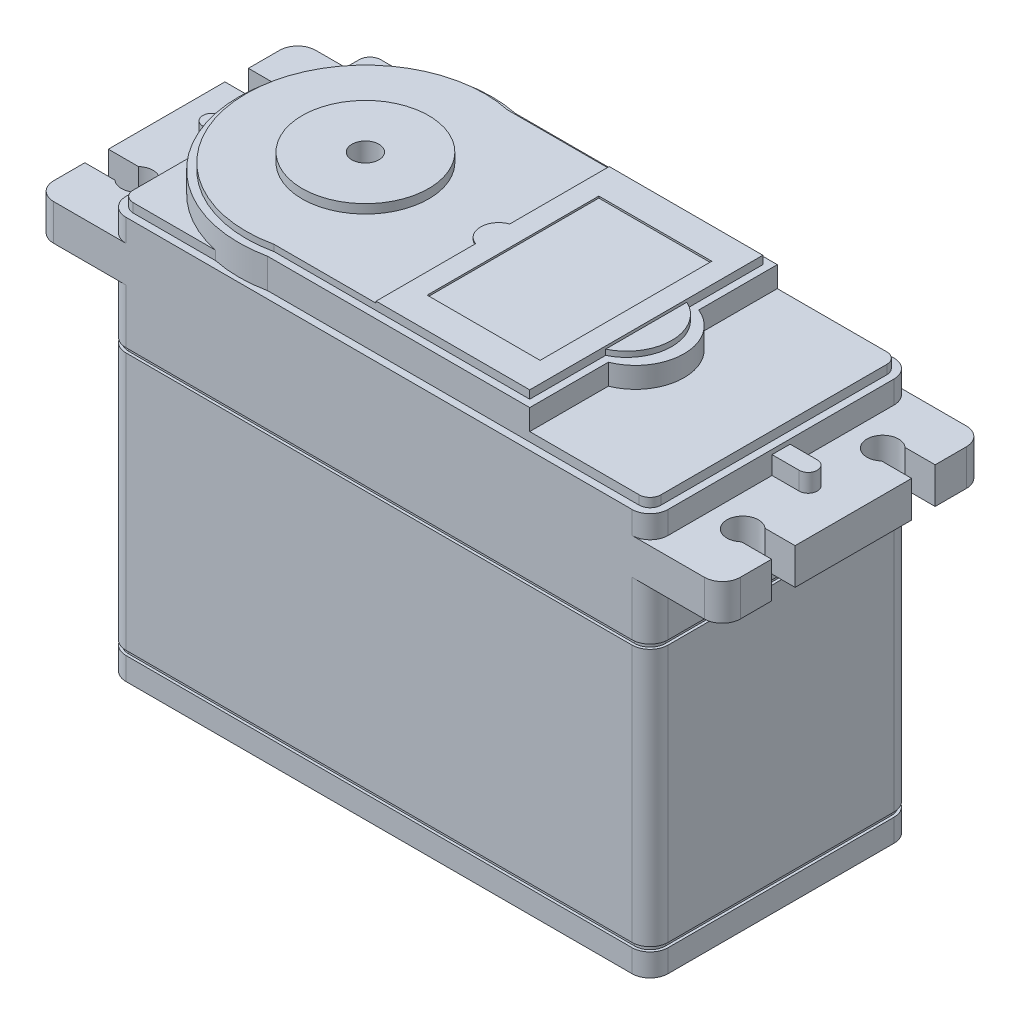
from build123d import *

# Parameters (mm, degrees)
SKETCH2_W            = 60
SKETCH2_H            = 29
BOSS_EXTRUDE1_DEPTH  = 46.5
FILLET1_R            = 2
BOSS_EXTRUDE2_DEPTH  = 4
BOSS_EXTRUDE3_DEPTH  = 2
CUT_EXTRUDE1_DEPTH   = 1
BOSS_EXTRUDE4_START  = -1
BOSS_EXTRUDE4_DEPTH  = 4
CUT_EXTRUDE2_DEPTH   = 0.7
BOSS_EXTRUDE5_REACH  = 50.8
BOSS_EXTRUDE6_DEPTH  = 0.6
CUT_EXTRUDE3_DEPTH   = 0.5
CUT_EXTRUDE4_DEPTH   = 0.5
CHAMFER1_SIZE        = 1
CUT_EXTRUDE5_DEPTH   = 1
SKETCH15_R           = 2
BOSS_EXTRUDE7_DEPTH  = 0.9
FILLET2_R            = 0.3
SKETCH16_R           = 7
BOSS_EXTRUDE8_DEPTH  = 1
SKETCH17_R           = 1.5
CUT_EXTRUDE6_DEPTH   = 10
BOSS_EXTRUDE9_DEPTH  = 0.2
SKETCH19_W           = 12.5
SKETCH19_H           = 19
CUT_EXTRUDE7_DEPTH   = 0.2
SKETCH21_W           = 6.5
SKETCH21_H           = 4.5
BOSS_EXTRUDE10_DEPTH = 5.2
CUT_EXTRUDE13_REACH  = 19.75
SKETCH25_W           = 5.5
SKETCH25_H           = 1.5
CUT_EXTRUDE14_DEPTH  = 7.2


with BuildPart() as part:
    # Sketch2 → Boss-Extrude1 (new body)
    with BuildSketch(Plane(origin=(0, 0, 0), x_dir=(1, 0, 0), z_dir=(0, 1, 0))):
        Rectangle(SKETCH2_W, SKETCH2_H)
    extrude(amount=BOSS_EXTRUDE1_DEPTH)

    # Fillet1
    fillet1_edges = [part.edges().sort_by_distance(p)[0] for p in [
        (30, 23.25, 14.5),
        (-30, 23.25, 14.5),
        (-30, 23.25, -14.5),
        (30, 23.25, -14.5),
    ]]
    fillet(fillet1_edges, radius=FILLET1_R)

    # Sketch4 → Boss-Extrude2 (add)
    with BuildSketch(Plane(origin=(0, 43, 0), x_dir=(1, 0, 0), z_dir=(0, 1, 0))):
        with BuildLine():
            Line((28, 14.5), (36, 14.5))
            ThreePointArc((36, 14.5), (37.414213562, 13.914213562), (38, 12.5))
            Line((38, 12.5), (38, 9.05))
            Line((38, 9.05), (34.671537451, 9.05))
            ThreePointArc((34.671537451, 9.05), (31.75, 7.75), (34.671537451, 6.45))
            Line((34.671537451, 6.45), (38, 6.45))
            Line((38, 6.45), (38, -6.45))
            Line((38, -6.45), (34.671537451, -6.45))
            ThreePointArc((34.671537451, -6.45), (31.75, -7.75), (34.671537451, -9.05))
            Line((34.671537451, -9.05), (38, -9.05))
            Line((38, -9.05), (38, -12.5))
            ThreePointArc((38, -12.5), (37.414213562, -13.914213562), (36, -14.5))
            Line((36, -14.5), (28, -14.5))
            ThreePointArc((28, -14.5), (29.414213562, -13.914213562), (30, -12.5))
            Line((30, -12.5), (30, 12.5))
            ThreePointArc((30, 12.5), (29.414213562, 13.914213562), (28, 14.5))
        make_face()
        with BuildLine():
            Line((-30, -12.5), (-30, 12.5))
            ThreePointArc((-30, 12.5), (-29.414213562, 13.914213562), (-28, 14.5))
            Line((-28, 14.5), (-36, 14.5))
            ThreePointArc((-36, 14.5), (-37.414213562, 13.914213562), (-38, 12.5))
            Line((-38, 12.5), (-38, 9.05))
            Line((-38, 9.05), (-34.671537451, 9.05))
            ThreePointArc((-34.671537451, 9.05), (-31.75, 7.75), (-34.671537451, 6.45))
            Line((-34.671537451, 6.45), (-38, 6.45))
            Line((-38, 6.45), (-38, -6.45))
            Line((-38, -6.45), (-34.671537451, -6.45))
            ThreePointArc((-34.671537451, -6.45), (-31.75, -7.75), (-34.671537451, -9.05))
            Line((-34.671537451, -9.05), (-38, -9.05))
            Line((-38, -9.05), (-38, -12.5))
            ThreePointArc((-38, -12.5), (-37.414213562, -13.914213562), (-36, -14.5))
            Line((-36, -14.5), (-28, -14.5))
            ThreePointArc((-28, -14.5), (-29.414213562, -13.914213562), (-30, -12.5))
        make_face()
    extrude(amount=-BOSS_EXTRUDE2_DEPTH)

    # Sketch5 → Boss-Extrude3 (add)
    with BuildSketch(Plane(origin=(0, 43, 0), x_dir=(1, 0, 0), z_dir=(0, 1, 0))):
        with BuildLine():
            Line((30, 1), (33, 1))
            ThreePointArc((33, 1), (34, 0), (33, -1))
            Line((33, -1), (30, -1))
            Line((30, -1), (30, 1))
        make_face()
        with BuildLine():
            Line((-30, 1), (-30, -1))
            Line((-30, -1), (-33, -1))
            ThreePointArc((-33, -1), (-34, 0), (-33, 1))
            Line((-33, 1), (-30, 1))
        make_face()
    extrude(amount=BOSS_EXTRUDE3_DEPTH)

    # Sketch6 → Cut-Extrude1 (cut)
    with BuildSketch(Plane(origin=(0, 46.5, 0), x_dir=(1, 0, 0), z_dir=(0, 1, 0))):
        with BuildLine():
            ThreePointArc((30, 12.5), (29.414213562, 13.914213562), (28, 14.5))
            Line((28, 14.5), (-28, 14.5))
            ThreePointArc((-28, 14.5), (-29.414213562, 13.914213562), (-30, 12.5))
            Line((-30, 12.5), (-30, -12.5))
            ThreePointArc((-30, -12.5), (-29.414213562, -13.914213562), (-28, -14.5))
            Line((-28, -14.5), (28, -14.5))
            ThreePointArc((28, -14.5), (29.414213562, -13.914213562), (30, -12.5))
            Line((30, -12.5), (30, 12.5))
        make_face()
        with BuildLine():
            ThreePointArc((29.2, 12.5), (28.848528137, 13.348528137), (28, 13.7))
            Line((28, 13.7), (-28, 13.7))
            ThreePointArc((-28, 13.7), (-28.848528137, 13.348528137), (-29.2, 12.5))
            Line((-29.2, 12.5), (-29.2, -12.5))
            ThreePointArc((-29.2, -12.5), (-28.848528137, -13.348528137), (-28, -13.7))
            Line((-28, -13.7), (28, -13.7))
            ThreePointArc((28, -13.7), (28.848528137, -13.348528137), (29.2, -12.5))
            Line((29.2, -12.5), (29.2, 12.5))
        make_face(mode=Mode.SUBTRACT)
    extrude(amount=-CUT_EXTRUDE1_DEPTH, mode=Mode.SUBTRACT)

    # Sketch7 → Boss-Extrude4 (add)
    with BuildSketch(Plane(origin=(0, 46.5, 0), x_dir=(1, 0, 0), z_dir=(0, 1, 0)).offset(BOSS_EXTRUDE4_START)):
        with BuildLine():
            Line((15.882707061, 13.7), (-13.117292939, 13.7))
            ThreePointArc((-13.117292939, 13.7), (-30, 0), (-13.117292939, -13.7))
            Line((-13.117292939, -13.7), (15.882707061, -13.7))
            Line((15.882707061, -13.7), (15.882707061, 13.7))
        make_face()
    extrude(amount=BOSS_EXTRUDE4_DEPTH)

    # Sketch8 → Cut-Extrude2 (cut)
    with BuildSketch(Plane(origin=(0, 49.5, 0), x_dir=(1, 0, 0), z_dir=(0, 1, 0))):
        with BuildLine():
            Line((15.882707061, -13.7), (15.882707061, 13.7))
            Line((15.882707061, 13.7), (-13.117292939, 13.7))
            ThreePointArc((-13.117292939, 13.7), (-30, 0), (-13.117292939, -13.7))
            Line((-13.117292939, -13.7), (15.882707061, -13.7))
        make_face()
        with BuildLine():
            Line((-13.201786284, -12.9), (15.082707061, -12.9))
            Line((15.082707061, -12.9), (15.082707061, 12.9))
            Line((15.082707061, 12.9), (-13.201786284, 12.9))
            ThreePointArc((-13.201786284, 12.9), (-29.2, 0), (-13.201786284, -12.9))
        make_face(mode=Mode.SUBTRACT)
    extrude(amount=-CUT_EXTRUDE2_DEPTH, mode=Mode.SUBTRACT)

    # Sketch9 → Boss-Extrude5 (add, up to next)
    with BuildSketch(Plane(origin=(0, 48.8, 0), x_dir=(1, 0, 0), z_dir=(0, 1, 0)), mode=Mode.PRIVATE) as boss_extrude5_sk1:
        with BuildLine():
            Line((15.882707061, 5), (15.882707061, -5))
            ThreePointArc((15.882707061, -5), (19.267871868, 0), (15.882707061, 5))
        make_face()
    boss_extrude5_tool1 = extrude(boss_extrude5_sk1.sketch, amount=-BOSS_EXTRUDE5_REACH, mode=Mode.PRIVATE) - part.part
    add(boss_extrude5_tool1.solids().sort_by_distance((17.281514, 48.8, 0))[0])

    # Sketch10 → Boss-Extrude6 (add)
    with BuildSketch(Plane(origin=(0, 48.8, 0), x_dir=(1, 0, 0), z_dir=(0, 1, 0))):
        with BuildLine():
            Line((15.082707061, 4.5), (15.082707061, -4.5))
            ThreePointArc((15.082707061, -4.5), (17.903257589, 0), (15.082707061, 4.5))
        make_face()
    extrude(amount=BOSS_EXTRUDE6_DEPTH)

    # Sketch11 → Cut-Extrude3 (cut)
    with BuildSketch(Plane(origin=(0, 3.5, 0), x_dir=(1, 0, 0), z_dir=(0, 1, 0))):
        with BuildLine():
            Line((-30, 12.5), (-30, -12.5))
            ThreePointArc((-30, -12.5), (-29.414213562, -13.914213562), (-28, -14.5))
            Line((-28, -14.5), (28, -14.5))
            ThreePointArc((28, -14.5), (29.414213562, -13.914213562), (30, -12.5))
            Line((30, -12.5), (30, 12.5))
            ThreePointArc((30, 12.5), (29.414213562, 13.914213562), (28, 14.5))
            Line((28, 14.5), (-28, 14.5))
            ThreePointArc((-28, 14.5), (-29.414213562, 13.914213562), (-30, 12.5))
        make_face()
        with BuildLine():
            Line((-28, -14.2), (28, -14.2))
            ThreePointArc((28, -14.2), (29.202081528, -13.702081528), (29.7, -12.5))
            Line((29.7, -12.5), (29.7, 12.5))
            ThreePointArc((29.7, 12.5), (29.202081528, 13.702081528), (28, 14.2))
            Line((28, 14.2), (-28, 14.2))
            ThreePointArc((-28, 14.2), (-29.202081528, 13.702081528), (-29.7, 12.5))
            Line((-29.7, 12.5), (-29.7, -12.5))
            ThreePointArc((-29.7, -12.5), (-29.202081528, -13.702081528), (-28, -14.2))
        make_face(mode=Mode.SUBTRACT)
    extrude(amount=CUT_EXTRUDE3_DEPTH, mode=Mode.SUBTRACT)

    # Sketch12 → Cut-Extrude4 (cut)
    with BuildSketch(Plane(origin=(0, 33, 0), x_dir=(1, 0, 0), z_dir=(0, 1, 0))):
        with BuildLine():
            Line((-30, 12.5), (-30, -12.5))
            ThreePointArc((-30, -12.5), (-29.414213562, -13.914213562), (-28, -14.5))
            Line((-28, -14.5), (28, -14.5))
            ThreePointArc((28, -14.5), (29.414213562, -13.914213562), (30, -12.5))
            Line((30, -12.5), (30, 12.5))
            ThreePointArc((30, 12.5), (29.414213562, 13.914213562), (28, 14.5))
            Line((28, 14.5), (-28, 14.5))
            ThreePointArc((-28, 14.5), (-29.414213562, 13.914213562), (-30, 12.5))
        make_face()
        with BuildLine():
            Line((28, 14.2), (-28, 14.2))
            ThreePointArc((-28, 14.2), (-29.202081528, 13.702081528), (-29.7, 12.5))
            Line((-29.7, 12.5), (-29.7, -12.5))
            ThreePointArc((-29.7, -12.5), (-29.202081528, -13.702081528), (-28, -14.2))
            Line((-28, -14.2), (28, -14.2))
            ThreePointArc((28, -14.2), (29.202081528, -13.702081528), (29.7, -12.5))
            Line((29.7, -12.5), (29.7, 12.5))
            ThreePointArc((29.7, 12.5), (29.202081528, 13.702081528), (28, 14.2))
        make_face(mode=Mode.SUBTRACT)
    extrude(amount=-CUT_EXTRUDE4_DEPTH, mode=Mode.SUBTRACT)

    # Chamfer1
    chamfer1_edges = [part.edges().sort_by_distance(p)[0] for p in [
        (-30, 0, 0),
        (30, 0, 0),
        (0, 0, 14.5),
        (0, 0, -14.5),
        (29.414213562, 0, 13.914213562),
        (29.414213562, 0, -13.914213562),
        (-29.414213562, 0, 13.914213562),
        (-29.414213562, 0, -13.914213562),
    ]]
    chamfer(chamfer1_edges, length=CHAMFER1_SIZE)

    # Sketch14 → Cut-Extrude5 (cut)
    with BuildSketch(Plane.XZ):
        with BuildLine():
            Line((-30, 8.1), (-25, 8.1))
            ThreePointArc((-25, 8.1), (-24.010050506, 8.510050506), (-23.6, 9.5))
            Line((-23.6, 9.5), (-23.6, 14.5))
            Line((-23.6, 14.5), (-28, 14.5))
            ThreePointArc((-28, 14.5), (-29.414213562, 13.914213562), (-30, 12.5))
            Line((-30, 12.5), (-30, 8.1))
        make_face()
        with BuildLine():
            Line((30, 8.1), (30, 12.5))
            ThreePointArc((30, 12.5), (29.414213562, 13.914213562), (28, 14.5))
            Line((28, 14.5), (23.6, 14.5))
            Line((23.6, 14.5), (23.6, 9.5))
            ThreePointArc((23.6, 9.5), (24.010050506, 8.510050506), (25, 8.1))
            Line((25, 8.1), (30, 8.1))
        make_face()
        with BuildLine():
            Line((30, -8.1), (25, -8.1))
            ThreePointArc((25, -8.1), (24.010050506, -8.510050506), (23.6, -9.5))
            Line((23.6, -9.5), (23.6, -14.5))
            Line((23.6, -14.5), (28, -14.5))
            ThreePointArc((28, -14.5), (29.414213562, -13.914213562), (30, -12.5))
            Line((30, -12.5), (30, -8.1))
        make_face()
        with BuildLine():
            Line((-30, -8.1), (-30, -12.5))
            ThreePointArc((-30, -12.5), (-29.414213562, -13.914213562), (-28, -14.5))
            Line((-28, -14.5), (-23.6, -14.5))
            Line((-23.6, -14.5), (-23.6, -9.5))
            ThreePointArc((-23.6, -9.5), (-24.010050506, -8.510050506), (-25, -8.1))
            Line((-25, -8.1), (-30, -8.1))
        make_face()
    extrude(amount=-CUT_EXTRUDE5_DEPTH, mode=Mode.SUBTRACT)

    # Sketch15 → Boss-Extrude7 (add)
    with BuildSketch(Plane.XZ.offset(-1)):
        with Locations((-26.8, 11.3)):
            Circle(SKETCH15_R)
        Polygon((-27.1, 11), (-27.1, 9.8), (-26.5, 9.8), (-26.5, 11), (-25.3, 11), (-25.3, 11.6), (-26.5, 11.6), (-26.5, 12.8), (-27.1, 12.8), (-27.1, 11.6), (-28.3, 11.6), (-28.3, 11), align=None, mode=Mode.SUBTRACT)
        with Locations((26.8, 11.3)):
            Circle(SKETCH15_R)
        Polygon((26.5, 11), (25.3, 11), (25.3, 11.6), (26.5, 11.6), (26.5, 12.8), (27.1, 12.8), (27.1, 11.6), (28.3, 11.6), (28.3, 11), (27.1, 11), (27.1, 9.8), (26.5, 9.8), align=None, mode=Mode.SUBTRACT)
        with Locations((26.8, -11.3)):
            Circle(SKETCH15_R)
        Polygon((27.1, -11), (27.1, -9.8), (26.5, -9.8), (26.5, -11), (25.3, -11), (25.3, -11.6), (26.5, -11.6), (26.5, -12.8), (27.1, -12.8), (27.1, -11.6), (28.3, -11.6), (28.3, -11), align=None, mode=Mode.SUBTRACT)
        with Locations((-26.8, -11.3)):
            Circle(SKETCH15_R)
        Polygon((-26.5, -11), (-25.3, -11), (-25.3, -11.6), (-26.5, -11.6), (-26.5, -12.8), (-27.1, -12.8), (-27.1, -11.6), (-28.3, -11.6), (-28.3, -11), (-27.1, -11), (-27.1, -9.8), (-26.5, -9.8), align=None, mode=Mode.SUBTRACT)
    extrude(amount=BOSS_EXTRUDE7_DEPTH)

    # Fillet2
    fillet2_edges = [part.edges().sort_by_distance(p)[0] for p in [
        (-28.8, 0.1, 11.3),
        (24.8, 0.1, 11.3),
        (24.8, 0.1, -11.3),
        (-28.8, 0.1, -11.3),
    ]]
    fillet(fillet2_edges, radius=FILLET2_R)

    # Sketch16 → Boss-Extrude8 (add)
    with BuildSketch(Plane(origin=(0, 49.5, 0), x_dir=(1, 0, 0), z_dir=(0, 1, 0))):
        with Locations((-16, 0)):
            Circle(SKETCH16_R)
    extrude(amount=BOSS_EXTRUDE8_DEPTH)

    # Sketch17 → Cut-Extrude6 (cut)
    with BuildSketch(Plane(origin=(0, 50.5, 0), x_dir=(1, 0, 0), z_dir=(0, 1, 0))):
        with Locations((-16, 0)):
            Circle(SKETCH17_R)
    extrude(amount=-CUT_EXTRUDE6_DEPTH, mode=Mode.SUBTRACT)

    # Sketch18 → Boss-Extrude9 (add)
    with BuildSketch(Plane(origin=(0, 49.5, 0), x_dir=(1, 0, 0), z_dir=(0, 1, 0))):
        with BuildLine():
            Line((-1.917292939, 12.9), (15.082707061, 12.9))
            Line((15.082707061, 12.9), (15.082707061, -12.9))
            Line((15.082707061, -12.9), (-1.917292939, -12.9))
            Line((-1.917292939, -12.9), (-1.917292939, -1.88563968))
            ThreePointArc((-1.917292939, -1.88563968), (-3.250687362, 0), (-1.917292939, 1.88563968))
            Line((-1.917292939, 1.88563968), (-1.917292939, 12.9))
        make_face()
    extrude(amount=BOSS_EXTRUDE9_DEPTH)

    # Sketch19 → Cut-Extrude7 (cut)
    with BuildSketch(Plane(origin=(0, 49.7, 0), x_dir=(1, 0, 0), z_dir=(0, 1, 0))):
        with Locations((6.582707061, 0)):
            Rectangle(SKETCH19_W, SKETCH19_H)
    extrude(amount=-CUT_EXTRUDE7_DEPTH, mode=Mode.SUBTRACT)

    # Sketch21 → Boss-Extrude10 (add)
    with BuildSketch(Plane.ZY.offset(30)):
        with Locations((0, 7)):
            Rectangle(SKETCH21_W, SKETCH21_H)
    extrude(amount=BOSS_EXTRUDE10_DEPTH)

    # Sketch24 → Cut-Extrude13 (cut, up to next)
    with BuildSketch(Plane(origin=(0, 0, -3.25), x_dir=(-1, 0, 0), z_dir=(0, 0, -1)), mode=Mode.PRIVATE) as cut_extrude13_sk1:
        Polygon((30, 9.25), (35.2, 9.25), (35.2, 8.25), align=None)
    cut_extrude13_tool1 = extrude(cut_extrude13_sk1.sketch, amount=-CUT_EXTRUDE13_REACH, mode=Mode.PRIVATE) & part.part
    add(cut_extrude13_tool1.solids().sort_by_distance((-33.466667, 8.916667, -3.25))[0], mode=Mode.SUBTRACT)
    # Sketch24 → Cut-Extrude13 (cut, up to next)
    with BuildSketch(Plane(origin=(0, 0, -3.25), x_dir=(-1, 0, 0), z_dir=(0, 0, -1)), mode=Mode.PRIVATE) as cut_extrude13_sk2:
        Polygon((35.2, 5.75), (30, 4.75), (35.2, 4.75), align=None)
    cut_extrude13_tool2 = extrude(cut_extrude13_sk2.sketch, amount=-CUT_EXTRUDE13_REACH, mode=Mode.PRIVATE) & part.part
    add(cut_extrude13_tool2.solids().sort_by_distance((-33.466667, 5.083333, -3.25))[0], mode=Mode.SUBTRACT)

    # Sketch25 → Cut-Extrude14 (cut)
    with BuildSketch(Plane.ZY.offset(35.2)):
        with Locations((0, 7)):
            Rectangle(SKETCH25_W, SKETCH25_H)
    extrude(amount=-CUT_EXTRUDE14_DEPTH, mode=Mode.SUBTRACT)


solid = part.part
